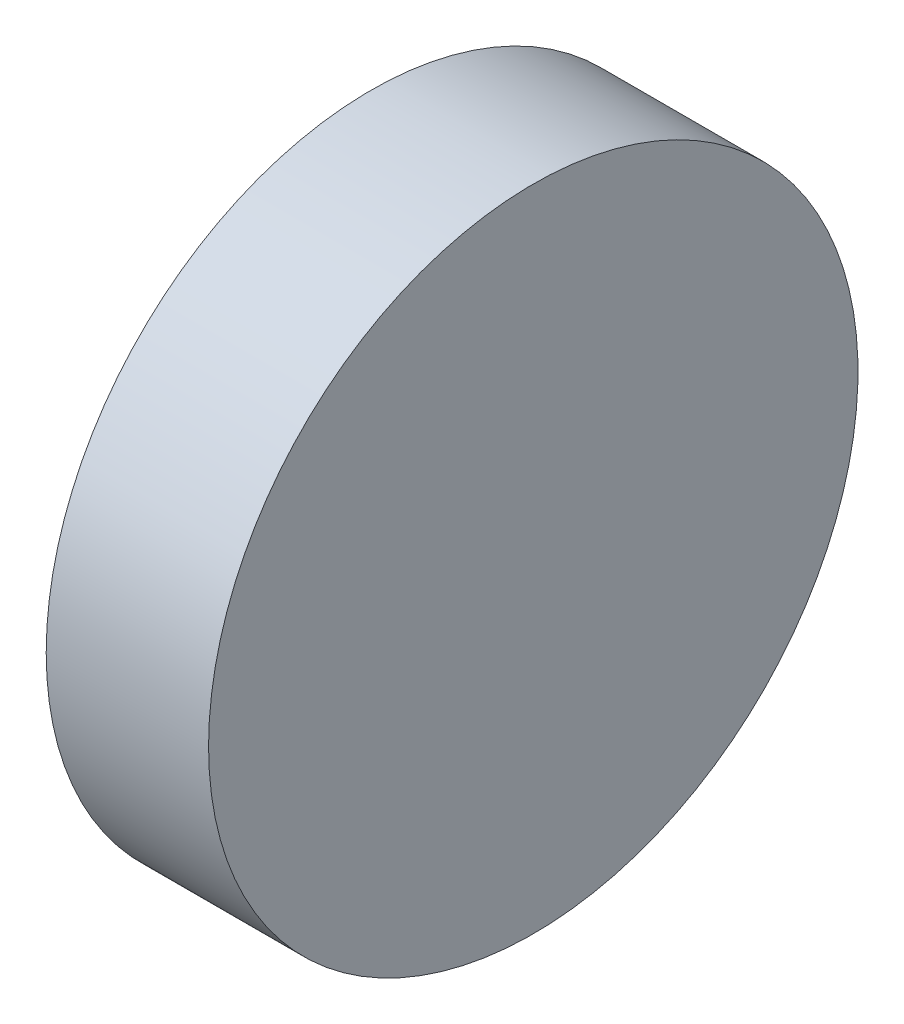
from build123d import *

# Parameters (mm, degrees)
SKETCH_1_W = 6.35
SKETCH_1_H = 12.7


with BuildPart() as part:
    # 草图1 → 旋转1 (revolve)
    with BuildSketch(Plane.XY, mode=Mode.PRIVATE) as revolve_1_sk:
        with Locations((262.899352893, 83.643179349)):
            Rectangle(SKETCH_1_W, SKETCH_1_H)
    revolve(revolve_1_sk.sketch.rotate(Axis((254.000801993, 77.293179349, 0), (1, 0, 0)), 90), axis=Axis((254.000801993, 77.293179349, 0), (1, 0, 0)))  # turned: the seam where the file's is


solid = part.part
